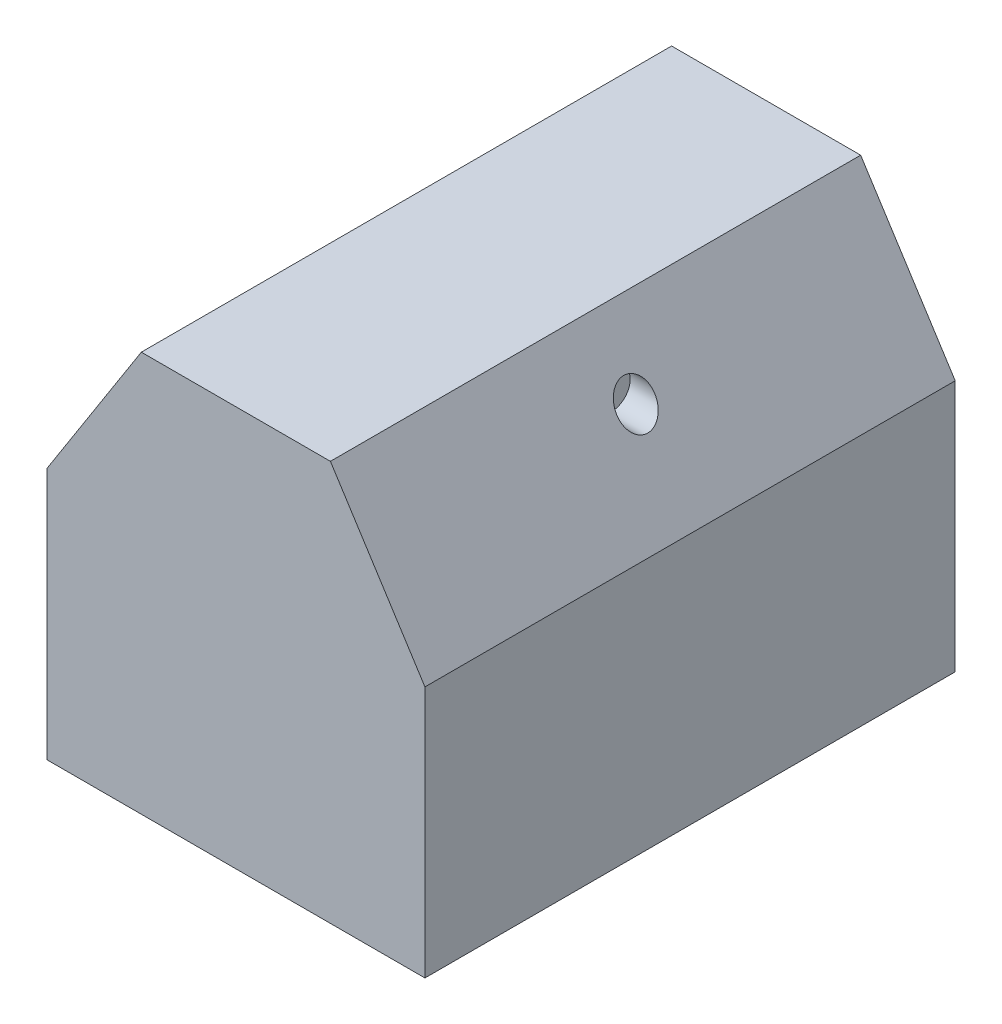
from build123d import *

# Parameters (mm, degrees)
RESSALTO_EXTRUS_O1_DEPTH = 84.1375
CORTE_EXTRUS_O1_START    = -35
ESBO_O2_R                = 6
CORTE_EXTRUS_O1_DEPTH    = 26


with BuildPart() as part:
    # Esboço1 → Ressalto-extrusão1 (new body, symmetric)
    with BuildSketch(Plane.XY):
        Polygon((-60, 0), (60, 0), (60, 80), (30, 127), (-30, 127), (-60, 80), align=None)
    extrude(amount=RESSALTO_EXTRUS_O1_DEPTH, both=True)

    # Esboço2 → Corte-extrusão1 (cut, through all)
    with BuildSketch(Plane(origin=(0, 0, 0), x_dir=(0, 0, -1), z_dir=(1, 0, 0)).offset(CORTE_EXTRUS_O1_START)):
        with Locations((0, 107)):
            Circle(ESBO_O2_R)
    corte_extrus_o1 = extrude(amount=-CORTE_EXTRUS_O1_DEPTH, mode=Mode.SUBTRACT)

    # Espelhar1: Corte-extrusão1 across plane
    add(corte_extrus_o1.mirror(Plane(origin=(0, 0, 0), x_dir=(0, 0, 1), z_dir=(1, 0, 0))), mode=Mode.SUBTRACT)


solid = part.part
